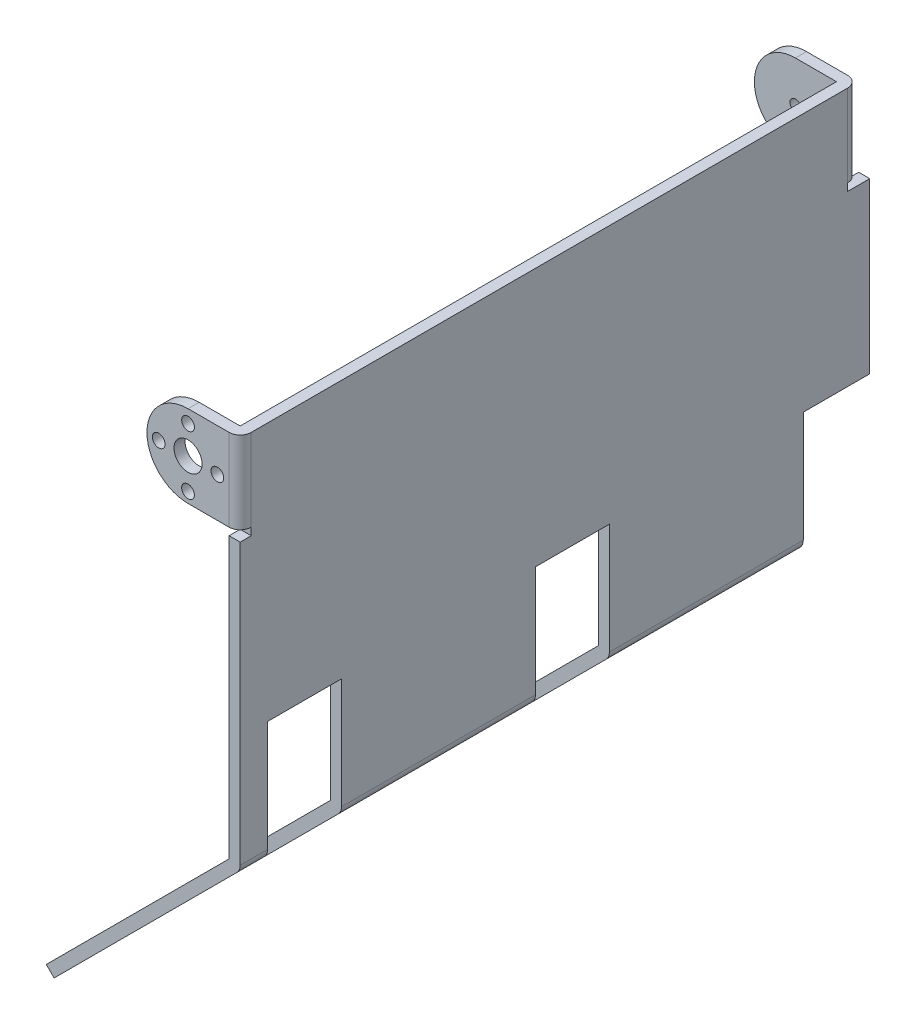
from build123d import *

# Parameters (mm, degrees)
BOSS_EXTRU_1_DEPTH      = 167.45
ESQUISSE2_W             = 20
ESQUISSE2_H             = 81.618795027
ESQUISSE2_W_2           = 15
ESQUISSE2_W_3           = 3
ESQUISSE2_H_2           = 2
ENL_V_MAT_EXTRU_1_DEPTH = 53.497474683
ESQUISSE3_R             = 3.8
ESQUISSE3_R_2           = 1.725
BOSS_EXTRU_2_DEPTH      = 3
ESQUISSE4_R             = 1.5
BOSS_EXTRU_3_DEPTH      = 3
ESQUISSE5_W             = 3
ESQUISSE5_H             = 45.77
BOSS_EXTRU_4_DEPTH      = 3
CONG_1_R                = 3


with BuildPart() as part:
    # Esquisse1 → Boss.-Extru.1 (new body)
    with BuildSketch(Plane.XY):
        with BuildLine():
            Line((-6.808328014, -1.100662076), (-56.305802697, -50.598136759))
            Line((-56.305802697, -50.598136759), (-54.184482354, -52.719457103))
            Line((-54.184482354, -52.719457103), (-4.687007671, -3.22198242))
            ThreePointArc((-4.687007671, -3.22198242), (-4.036689417, -2.248712373), (-3.808328014, -1.100662076))
            Line((-3.808328014, -1.100662076), (-3.808328014, 98.899337924))
            Line((-3.808328014, 98.899337924), (-6.808328014, 98.899337924))
            Line((-6.808328014, 98.899337924), (-6.808328014, -1.100662076))
        make_face()
    extrude(amount=BOSS_EXTRU_1_DEPTH)

    # Esquisse2 → Enlèv. mat.-Extru.1 (cut, through all)
    with BuildSketch(Plane(origin=(-3.808328014, 0, 0), x_dir=(0, 0, -1), z_dir=(1, 0, 0))):
        with Locations((-150, -11.91005959)):
            Rectangle(ESQUISSE2_W, ESQUISSE2_H)
        with Locations((-7.5, -11.91005959)):
            Rectangle(ESQUISSE2_W_2, ESQUISSE2_H)
        with Locations((-77.5, -11.91005959)):
            Rectangle(ESQUISSE2_W, ESQUISSE2_H)
        with Locations((-165.95, 75.669337924)):
            Rectangle(ESQUISSE2_W_3, ESQUISSE2_H_2)
        with Locations((-1.5, 75.669337924)):
            Rectangle(ESQUISSE2_W_3, ESQUISSE2_H_2)
    extrude(amount=-ENL_V_MAT_EXTRU_1_DEPTH, mode=Mode.SUBTRACT)

    # Esquisse3 → Boss.-Extru.2 (add)
    with BuildSketch(Plane.XY.offset(167.45)):
        with BuildLine():
            Line((-6.808328014, 98.899337924), (-17.923328014, 98.899337924))
            ThreePointArc((-17.923328014, 98.899337924), (-29.038328014, 87.784337924), (-17.923328014, 76.669337924))
            Line((-17.923328014, 76.669337924), (-6.808328014, 76.669337924))
            Line((-6.808328014, 76.669337924), (-6.808328014, 98.899337924))
        make_face()
        with Locations((-17.923328014, 87.784337924)):
            Circle(ESQUISSE3_R, mode=Mode.SUBTRACT)
        with Locations((-25.863328014, 87.453430664)):
            Circle(ESQUISSE3_R_2, mode=Mode.SUBTRACT)
        with Locations((-17.923328014, 95.393430664)):
            Circle(ESQUISSE3_R_2, mode=Mode.SUBTRACT)
        with Locations((-9.983328014, 87.453430664)):
            Circle(ESQUISSE3_R_2, mode=Mode.SUBTRACT)
        with Locations((-17.923328014, 79.513430664)):
            Circle(ESQUISSE3_R_2, mode=Mode.SUBTRACT)
    extrude(amount=-BOSS_EXTRU_2_DEPTH)

    # Esquisse4 → Boss.-Extru.3 (add)
    with BuildSketch(Plane(origin=(0, 0, 0), x_dir=(-1, 0, 0), z_dir=(0, 0, -1))):
        with BuildLine():
            Line((6.808328014, 98.899337924), (17.923328014, 98.899337924))
            ThreePointArc((17.923328014, 98.899337924), (29.038328014, 87.784337924), (17.923328014, 76.669337924))
            Line((17.923328014, 76.669337924), (6.808328014, 76.669337924))
            Line((6.808328014, 76.669337924), (6.808328014, 98.899337924))
        make_face()
        with Locations((17.923328014, 87.784337924)):
            Circle(ESQUISSE4_R, mode=Mode.SUBTRACT)
    extrude(amount=-BOSS_EXTRU_3_DEPTH)

    # Esquisse5 → Boss.-Extru.4 (add)
    with BuildSketch(Plane(origin=(0, 0, 0), x_dir=(-1, 0, 0), z_dir=(0, 0, -1))):
        with Locations((5.308328014, 51.784337924)):
            Rectangle(ESQUISSE5_W, ESQUISSE5_H)
    extrude(amount=BOSS_EXTRU_4_DEPTH)

    # Congé1
    cong_1_edges = [part.edges().sort_by_distance(p)[0] for p in [
        (-3.808328014, 87.784337924, 0),
        (-3.808328014, 87.784337924, 167.45),
    ]]
    fillet(cong_1_edges, radius=CONG_1_R)


solid = part.part
